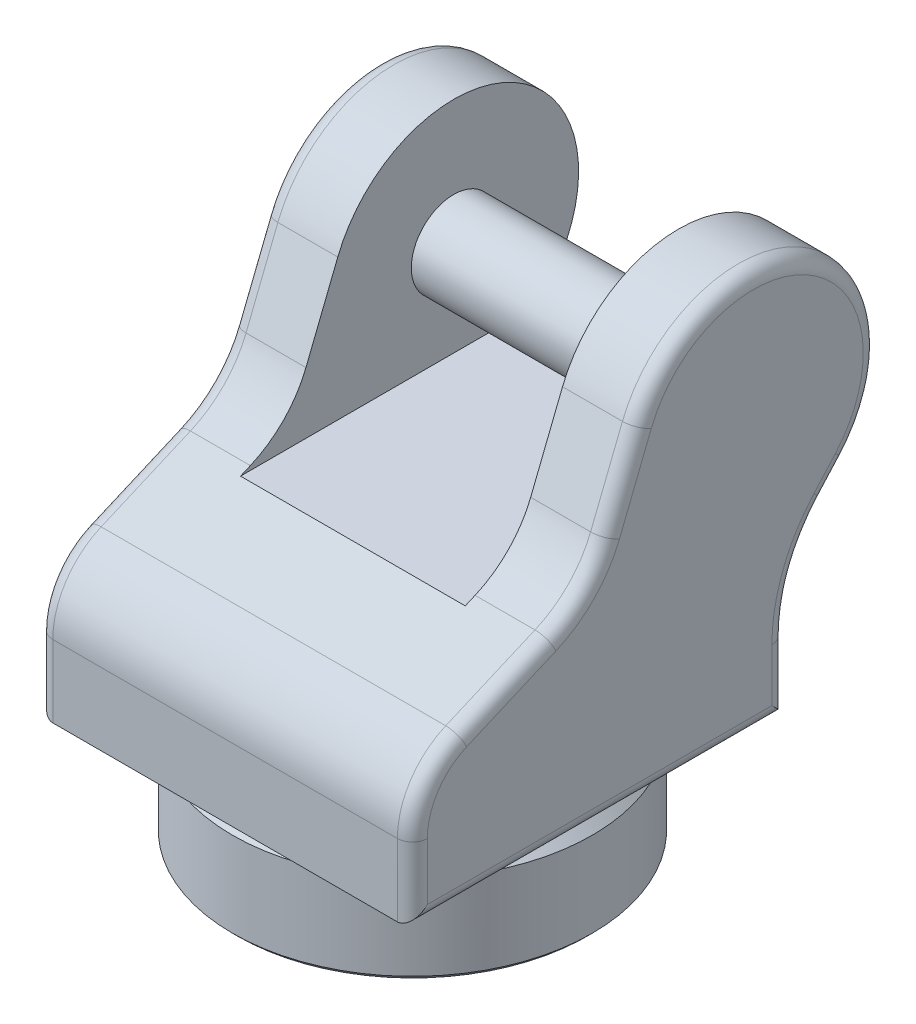
from build123d import *

# Parameters (mm, degrees)
CHAMFER1_SIZE           = 10
CHAMFER2_SIZE           = 5
CHAMFER3_SIZE           = 5
SKETCH4_R               = 160
BOSS_EXTRUDE1_DEPTH     = 5
BOSS_EXTRUDE2_DEPTH     = 187.5
FILLET1_R               = 15
SKETCH6_W               = 225
SKETCH6_H               = 220
CUT_EXTRUDE1_DEPTH      = 188.562818856
CUT_EXTRUDE1_DEPTH_BACK = 279.899051912
SKETCH7_R               = 42.5
BOSS_EXTRUDE3_DEPTH     = 225
SKETCH8_W               = 10
SKETCH8_H               = 12.5


with BuildPart() as part:
    # Sketch2 → Revolve1 (revolve)
    with BuildSketch(Plane.XY):
        Polygon((-160, 0), (-160, 20), (-150, 20), (-150, 80), (0, 80), (0, 100), (-180, 100), (-180, 0), align=None)
    revolve(axis=Axis((0, 100, 0), (0, -1, 0)))

    # Chamfer1
    chamfer1_edges = [part.edges().sort_by_distance(p)[0] for p in [
        (180, 100, 0),
    ]]
    chamfer(chamfer1_edges, length=CHAMFER1_SIZE)

    # Chamfer2
    chamfer2_edges = [part.edges().sort_by_distance(p)[0] for p in [
        (150, 80, 0),
        (160, 0, 0),
    ]]
    chamfer(chamfer2_edges, length=CHAMFER2_SIZE)

    # Chamfer3
    chamfer3_edges = [part.edges().sort_by_distance(p)[0] for p in [
        (180, 0, 0),
    ]]
    chamfer(chamfer3_edges, length=CHAMFER3_SIZE)

    # Sketch4 → Boss-Extrude1 (add)
    with BuildSketch(Plane(origin=(0, 100, 0), x_dir=(1, 0, 0), z_dir=(0, 1, 0))):
        Circle(SKETCH4_R)
    extrude(amount=BOSS_EXTRUDE1_DEPTH)

    # Sketch5 → Boss-Extrude2 (add, symmetric)
    with BuildSketch(Plane(origin=(0, 0, 0), x_dir=(0, 0, -1), z_dir=(1, 0, 0))):
        with BuildLine():
            Line((187.437181144, 105), (-187.562818856, 105))
            Line((-187.562818856, 105), (-187.562818856, 177.307219005))
            ThreePointArc((-187.562818856, 177.307219005), (-174.372707713, 221.312204528), (-139.151850084, 250.806423804))
            Line((-139.151850084, 250.806423804), (-49.751809858, 289.229433552))
            ThreePointArc((-49.751809858, 289.229433552), (-16.228261208, 312.275925599), (5.923948566, 346.397014559))
            Line((5.923948566, 346.397014559), (37.791857566, 426.304637395))
            ThreePointArc((37.791857566, 426.304637395), (219.726126853, 486.262863652), (247.066543683, 296.664422612))
            Line((247.066543683, 296.664422612), (225.636190899, 272.705721163))
            ThreePointArc((225.636190899, 272.705721163), (197.31197189, 226.228029294), (187.437181144, 172.703028297))
            Line((187.437181144, 172.703028297), (187.437181144, 105))
        make_face()
    extrude(amount=BOSS_EXTRUDE2_DEPTH, both=True)

    # Fillet1
    fillet1_edges = [part.edges().sort_by_distance(p)[0] for p in [
        (-187.5, 141.153609503, 187.562818856),
        (-187.5, 105, 0.062818856),
        (-187.5, 138.851514149, -187.437181144),
        (-187.5, 226.228029294, -197.31197189),
        (-187.5, 284.685071887, -236.351367291),
        (-187.5, 486.262863652, -219.726126853),
        (-187.5, 386.350825977, -21.857903066),
        (-187.5, 312.275925599, 16.228261208),
        (-187.5, 270.017928678, 94.451829971),
        (-187.5, 221.312204528, 174.372707713),
        (187.5, 141.153609503, 187.562818856),
        (187.5, 105, 0.062818856),
        (187.5, 138.851514149, -187.437181144),
        (187.5, 226.228029294, -197.31197189),
        (187.5, 284.685071887, -236.351367291),
        (187.5, 486.262863652, -219.726126853),
        (187.5, 386.350825977, -21.857903066),
        (187.5, 312.275925599, 16.228261208),
        (187.5, 270.017928678, 94.451829971),
        (187.5, 221.312204528, 174.372707713),
    ]]
    fillet(fillet1_edges, radius=FILLET1_R)

    # Sketch6 → Cut-Extrude1 (cut, two sides)
    with BuildSketch(Plane.XY) as cut_extrude1_sk:
        with Locations((0, 395)):
            Rectangle(SKETCH6_W, SKETCH6_H)
    extrude(amount=CUT_EXTRUDE1_DEPTH, mode=Mode.SUBTRACT)
    extrude(cut_extrude1_sk.sketch, amount=-CUT_EXTRUDE1_DEPTH_BACK, mode=Mode.SUBTRACT)

    # Sketch7 → Boss-Extrude3 (add)
    with BuildSketch(Plane.ZY.offset(-112.5)):
        with Locations((-153.899051812, 380)):
            Circle(SKETCH7_R)
    extrude(amount=BOSS_EXTRUDE3_DEPTH)

    # Sketch8 → Revolve2 (revolve)
    with BuildSketch(Plane.XY):
        with Locations((-145, 53.75)):
            Rectangle(SKETCH8_W, SKETCH8_H)
    revolve(axis=Axis((0, 0, 0), (0, 1, 0)))


solid = part.part
